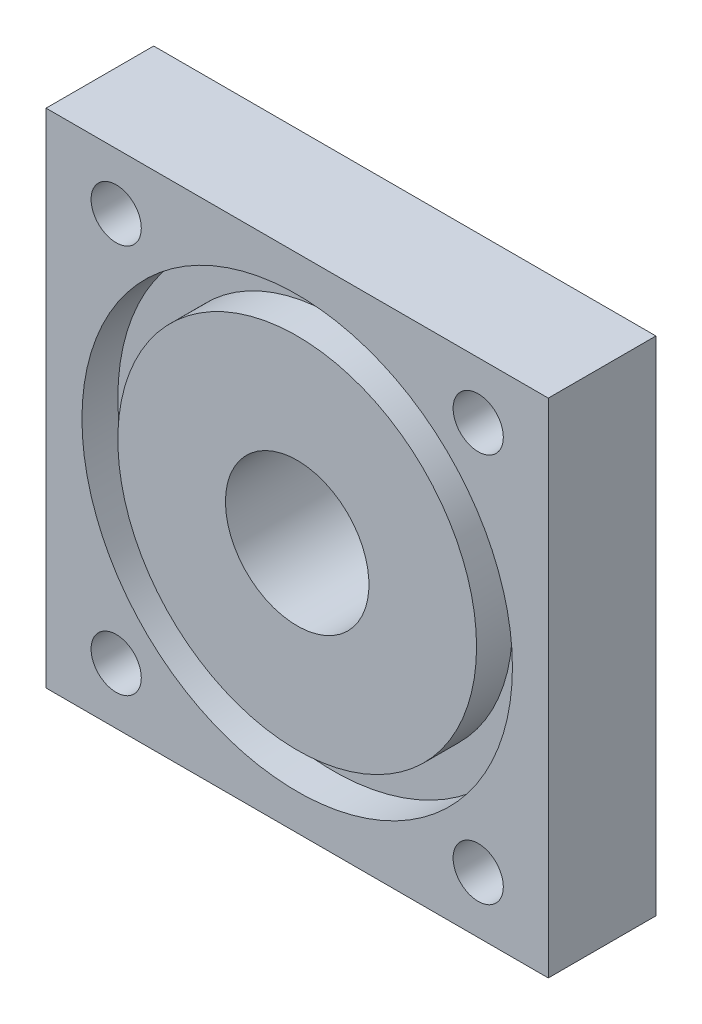
from build123d import *

# Parameters (mm, degrees)
SKETCH1_W           = 70
SKETCH1_H           = 70
BOSS_EXTRUDE1_DEPTH = 15
SKETCH2_R           = 30
SKETCH2_R_2         = 25
SKETCH2_R_3         = 3.5
CUT_EXTRUDE1_DEPTH  = 5
SKETCH3_R           = 3.5
CUT_EXTRUDE2_DEPTH  = 16
SKETCH4_R           = 10
CUT_EXTRUDE3_DEPTH  = 16


with BuildPart() as part:
    # Sketch1 → Boss-Extrude1 (new body)
    with BuildSketch(Plane.XY):
        Rectangle(SKETCH1_W, SKETCH1_H)
    extrude(amount=BOSS_EXTRUDE1_DEPTH)

    # Sketch2 → Cut-Extrude1 (cut)
    with BuildSketch(Plane.XY.offset(15)):
        Circle(SKETCH2_R)
        Circle(SKETCH2_R_2, mode=Mode.SUBTRACT)
        with Locations((-25.229863316, 27.137958195)):
            Circle(SKETCH2_R_3)
        with Locations((25.229863316, 27.137958195)):
            Circle(SKETCH2_R_3)
        with Locations((25.229863316, -27.137958195)):
            Circle(SKETCH2_R_3)
        with Locations((-25.229863316, -27.137958195)):
            Circle(SKETCH2_R_3)
    extrude(amount=-CUT_EXTRUDE1_DEPTH, mode=Mode.SUBTRACT)

    # Sketch3 → Cut-Extrude2 (cut, through all)
    with BuildSketch(Plane.XY):
        with Locations((-25.229863316, 27.137958195)):
            Circle(SKETCH3_R)
        with Locations((25.229863316, 27.137958195)):
            Circle(SKETCH3_R)
        with Locations((25.229863316, -27.137958195)):
            Circle(SKETCH3_R)
        with Locations((-25.229863316, -27.137958195)):
            Circle(SKETCH3_R)
    extrude(amount=CUT_EXTRUDE2_DEPTH, mode=Mode.SUBTRACT)

    # Sketch4 → Cut-Extrude3 (cut, through all)
    with BuildSketch(Plane(origin=(0, 0, 0), x_dir=(-1, 0, 0), z_dir=(0, 0, -1))):
        Circle(SKETCH4_R)
    extrude(amount=-CUT_EXTRUDE3_DEPTH, mode=Mode.SUBTRACT)


solid = part.part
